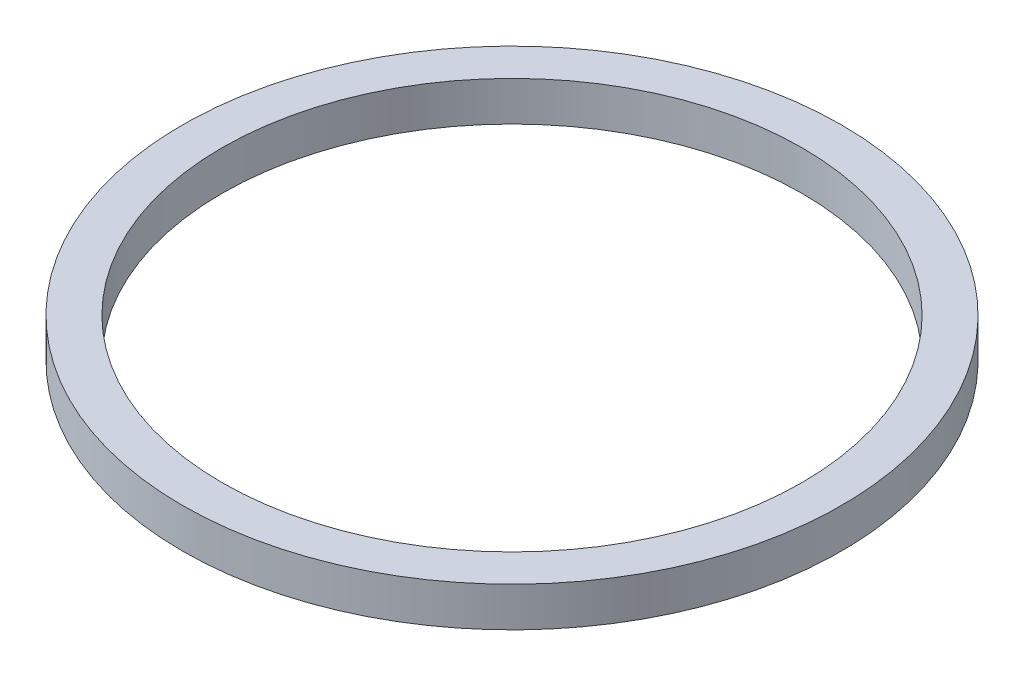
from build123d import *

# Parameters (mm, degrees)
SKETCH1_R           = 25
SKETCH1_R_2         = 22
BOSS_EXTRUDE1_DEPTH = 3


with BuildPart() as part:
    # Sketch1 → Boss-Extrude1 (new body)
    with BuildSketch(Plane(origin=(0, 0, 0), x_dir=(1, 0, 0), z_dir=(0, 1, 0))):
        Circle(SKETCH1_R)
        Circle(SKETCH1_R_2, mode=Mode.SUBTRACT)
    extrude(amount=BOSS_EXTRUDE1_DEPTH)


solid = part.part
